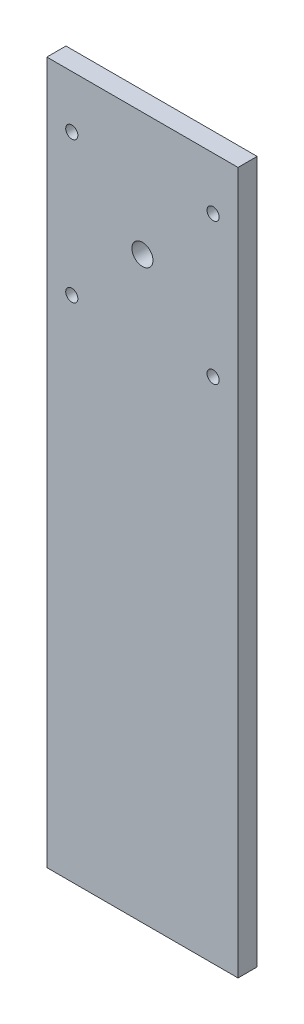
from build123d import *

# Parameters (mm, degrees)
SKETCH1_W                  = 63.5
SKETCH1_H                  = 233.172
SKETCH1_R                  = 3.4925
BOSS_EXTRUDE1_DEPTH        = 6.35
F_10_32_TAPPED_HOLE1_D     = 4.0386
F_10_32_TAPPED_HOLE1_DEPTH = 6.35


with BuildPart() as part:
    # Sketch1 → Boss-Extrude1 (new body)
    with BuildSketch(Plane.XY):
        with Locations((31.75, -116.586)):
            Rectangle(SKETCH1_W, SKETCH1_H)
        with Locations((31.75, -40.894)):
            Circle(SKETCH1_R, mode=Mode.SUBTRACT)
    extrude(amount=BOSS_EXTRUDE1_DEPTH)

    # #10-32 Tapped Hole1
    with Locations(Plane.XY.offset(6.35)):
        with Locations((8.2804, -17.4244), (55.2196, -17.4244), (55.2196, -64.3636), (8.2804, -64.3636)):
            Hole(F_10_32_TAPPED_HOLE1_D / 2, depth=F_10_32_TAPPED_HOLE1_DEPTH)


solid = part.part
